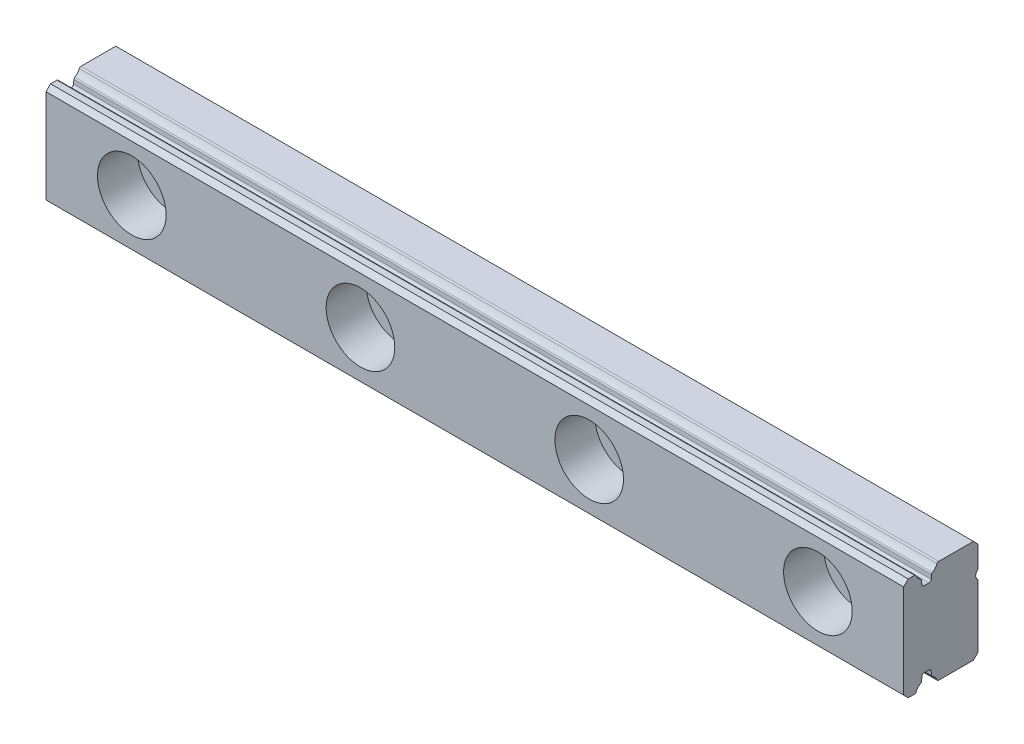
from build123d import *

# Parameters (mm, degrees)
BOSS_EXTRUDE1_DEPTH                              = 75
CBORE_FOR_M3_HEX_HEAD_MACHINE_SCREW2_D           = 3.5
CBORE_FOR_M3_HEX_HEAD_MACHINE_SCREW2_DEPTH       = 6.5
CBORE_FOR_M3_HEX_HEAD_MACHINE_SCREW2_CBORE_D     = 6
CBORE_FOR_M3_HEX_HEAD_MACHINE_SCREW2_CBORE_DEPTH = 3.5
LPATTERN2_COUNT                                  = 4
LPATTERN2_PITCH                                  = 20


with BuildPart() as part:
    # Sketch1 → Boss-Extrude1 (new body)
    with BuildSketch(Plane(origin=(67.5, 0, 0), x_dir=(0, 0, -1), z_dir=(1, 0, 0))):
        with BuildLine():
            Line((-3.441696476, -4.5), (-0.4, -4.5))
            Line((-0.4, -4.5), (0, -4.1))
            Line((0, -4.1), (0, 1.4))
            ThreePointArc((0, 1.4), (-0.2, 1.8), (0, 2.2))
            Line((0, 2.2), (0, 4.1))
            Line((0, 4.1), (-0.4, 4.5))
            Line((-0.4, 4.5), (-3.441696476, 4.5))
            ThreePointArc((-3.441696476, 4.5), (-3.524448068, 4.475108648), (-3.579735674, 4.408695652))
            ThreePointArc((-3.579735674, 4.408695652), (-3.747623907, 4.141262777), (-3.990528855, 3.939510483))
            ThreePointArc((-3.990528855, 3.939510483), (-4.041057421, 3.890337026), (-4.063537838, 3.823510417))
            Line((-4.063537838, 3.823510417), (-4.09336636, 3.482568852))
            ThreePointArc((-4.09336636, 3.482568852), (-4.157487258, 3.352544533), (-4.292605299, 3.3))
            Line((-4.292605299, 3.3), (-4.707394701, 3.3))
            ThreePointArc((-4.707394701, 3.3), (-4.842512742, 3.352544533), (-4.90663364, 3.482568852))
            Line((-4.90663364, 3.482568852), (-4.93646249, 3.823514163))
            ThreePointArc((-4.93646249, 3.823514163), (-4.958942652, 3.890340367), (-5.009470648, 3.939513741))
            ThreePointArc((-5.009470648, 3.939513741), (-5.252372199, 4.141265182), (-5.420258326, 4.408695652))
            ThreePointArc((-5.420258326, 4.408695652), (-5.475545932, 4.475108648), (-5.558297524, 4.5))
            Line((-5.558297524, 4.5), (-6.1, 4.5))
            Line((-6.1, 4.5), (-6.5, 4.1))
            Line((-6.5, 4.1), (-6.5, -4.1))
            Line((-6.5, -4.1), (-6.1, -4.5))
            Line((-6.1, -4.5), (-5.558297524, -4.5))
            ThreePointArc((-5.558297524, -4.5), (-5.475545932, -4.475108648), (-5.420258326, -4.408695652))
            ThreePointArc((-5.420258326, -4.408695652), (-5.252372199, -4.141265182), (-5.009470648, -3.939513741))
            ThreePointArc((-5.009470648, -3.939513741), (-4.958942652, -3.890340367), (-4.93646249, -3.823514163))
            Line((-4.93646249, -3.823514163), (-4.90663364, -3.482568852))
            ThreePointArc((-4.90663364, -3.482568852), (-4.842512742, -3.352544533), (-4.707394701, -3.3))
            Line((-4.707394701, -3.3), (-4.292605299, -3.3))
            ThreePointArc((-4.292605299, -3.3), (-4.157487258, -3.352544533), (-4.09336636, -3.482568852))
            Line((-4.09336636, -3.482568852), (-4.063537838, -3.823510417))
            ThreePointArc((-4.063537838, -3.823510417), (-4.041057421, -3.890337026), (-3.990528855, -3.939510483))
            ThreePointArc((-3.990528855, -3.939510483), (-3.747623907, -4.141262777), (-3.579735674, -4.408695652))
            ThreePointArc((-3.579735674, -4.408695652), (-3.524448068, -4.475108648), (-3.441696476, -4.5))
        make_face()
    extrude(amount=-BOSS_EXTRUDE1_DEPTH)

    # CBORE for M3 Hex Head Machine Screw2
    with Locations(Plane.XY.offset(6.5)):
        with Locations((0, 0)):
            cbore_for_m3_hex_head_machine_screw2 = CounterBoreHole(CBORE_FOR_M3_HEX_HEAD_MACHINE_SCREW2_D / 2, CBORE_FOR_M3_HEX_HEAD_MACHINE_SCREW2_CBORE_D / 2, CBORE_FOR_M3_HEX_HEAD_MACHINE_SCREW2_CBORE_DEPTH, depth=CBORE_FOR_M3_HEX_HEAD_MACHINE_SCREW2_DEPTH)

    # LPattern2: CBORE for M3 Hex Head Machine Screw2 ×4
    with Locations(*[(i * LPATTERN2_PITCH, 0, 0) for i in range(1, LPATTERN2_COUNT)]):
        add(cbore_for_m3_hex_head_machine_screw2, mode=Mode.SUBTRACT)


solid = part.part
